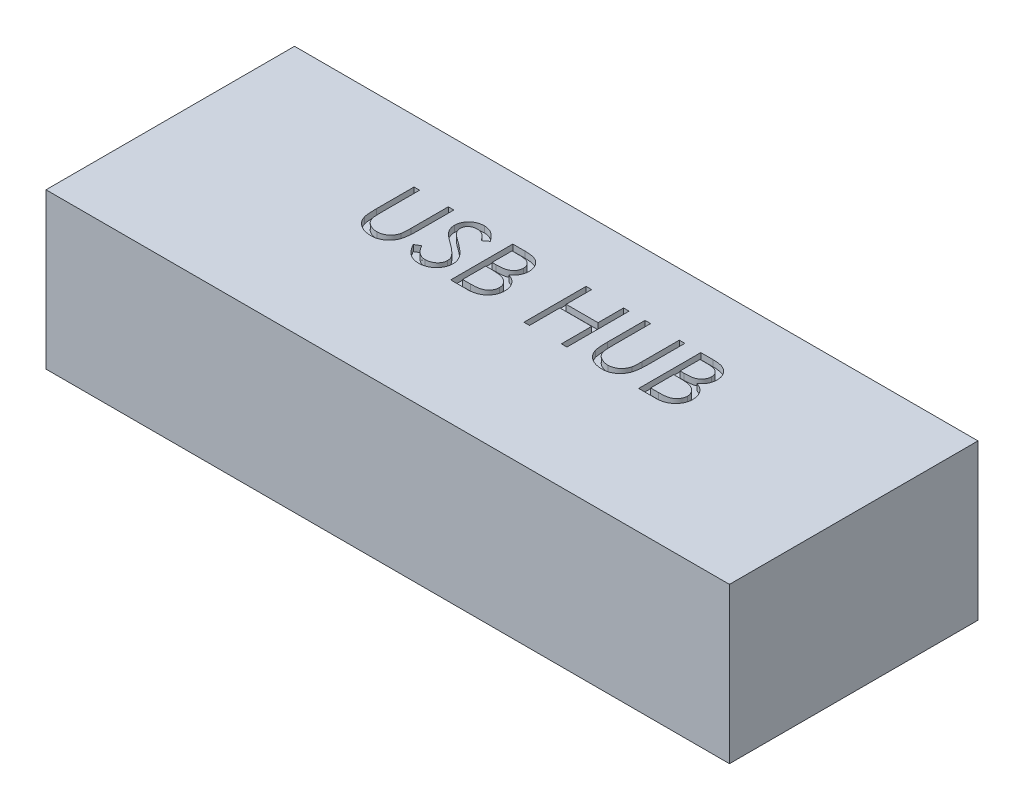
from build123d import *

# Parameters (mm, degrees)
SKETCH1_W           = 110
SKETCH1_H           = 40
BOSS_EXTRUDE1_DEPTH = 25
CUT_EXTRUDE1_DEPTH  = 1


with BuildPart() as part:
    # Sketch1 → Boss-Extrude1 (new body)
    with BuildSketch(Plane(origin=(0, 0, 0), x_dir=(1, 0, 0), z_dir=(0, 1, 0))):
        with Locations((55, 20)):
            Rectangle(SKETCH1_W, SKETCH1_H)
    extrude(amount=BOSS_EXTRUDE1_DEPTH)

    # Sketch2 → Cut-Extrude1 (cut)
    with BuildSketch(Plane(origin=(0, 25, 0), x_dir=(1, 0, 0), z_dir=(0, 1, 0))):
        with BuildLine():
            Line((29.230769231, 30), (30.128205128, 30))
            Line((30.128205128, 30), (30.128205128, 24.008413462))
            add(Edge.make_bspline(
                [(30.128205128, 24.008413462), (30.128071574, 23.923611359), (30.127818132, 23.762684757), (30.129511029, 23.533632469), (30.134252081, 23.329996872), (30.137241109, 23.150993022), (30.143890633, 22.997442315), (30.149313624, 22.868512856), (30.156286643, 22.764815135), (30.164666979, 22.704298203), (30.168269231, 22.678285256)],
                knots=[0, 0, 0, 0, 1.528628734, 2.90083645, 4.128790002, 5.200304208, 6.127813768, 6.898992206, 7.526736466, 8, 8, 8, 8], degree=3))
            add(Edge.make_bspline(
                [(30.168269231, 22.678285256), (30.18306197, 22.584437361), (30.211813931, 22.402029564), (30.285089296, 22.142291615), (30.387425013, 21.908201735), (30.50869085, 21.692455189), (30.668498311, 21.501057017), (30.859936983, 21.324738009), (31.091873464, 21.170532853), (31.349760909, 21.029530533), (31.627718731, 20.916201727), (31.91175092, 20.8305064), (32.197588004, 20.778280972), (32.388948475, 20.772233718), (32.483974359, 20.769230769)],
                knots=[0, 0, 0, 0, 1.035780045, 2.013197591, 2.933192213, 3.817615948, 4.702609284, 5.640816605, 6.646850145, 7.73207398, 8.84249596, 9.914020372, 10.964143139, 12, 12, 12, 12], degree=3))
            add(Edge.make_bspline(
                [(32.483974359, 20.769230769), (32.565556474, 20.772298913), (32.728249508, 20.778417479), (32.969982167, 20.816307282), (33.205411049, 20.884594613), (33.435698706, 20.972708208), (33.651558662, 21.089129897), (33.853111353, 21.22361801), (34.033008308, 21.38136337), (34.197174016, 21.555935783), (34.340130976, 21.75290664), (34.464048523, 21.967987034), (34.565551179, 22.20441374), (34.615675536, 22.370569232), (34.641426282, 22.455929487)],
                knots=[0, 0, 0, 0, 0.994687771, 1.983630487, 2.973142513, 3.978332533, 4.983357753, 5.956394766, 6.925816176, 7.893390482, 8.871859704, 9.88551698, 10.913711441, 12, 12, 12, 12], degree=3))
            add(Edge.make_bspline(
                [(34.641426282, 22.455929487), (34.649998069, 22.491211128), (34.669099463, 22.569832843), (34.686948163, 22.702750816), (34.705538236, 22.85957757), (34.718437007, 23.041439892), (34.731011923, 23.247728385), (34.738534988, 23.479517692), (34.742012225, 23.735966152), (34.743048455, 23.914929471), (34.743589744, 24.008413462)],
                knots=[0, 0, 0, 0, 0.558680831, 1.244966039, 2.062412453, 2.990489873, 4.051219941, 5.244515665, 6.560634259, 8, 8, 8, 8], degree=3))
            Line((34.743589744, 24.008413462), (34.743589744, 30))
            Line((34.743589744, 30), (35.641025641, 30))
            Line((35.641025641, 30), (35.641025641, 23.960336538))
            add(Edge.make_bspline(
                [(35.641025641, 23.960336538), (35.640299583, 23.851484027), (35.638882636, 23.639051733), (35.626595275, 23.327762136), (35.607003846, 23.032467904), (35.579323595, 22.753129342), (35.542646443, 22.49074603), (35.501860099, 22.243018121), (35.449918576, 22.011723856), (35.389251715, 21.795059806), (35.319898721, 21.588815482), (35.230066869, 21.393076583), (35.128854012, 21.201892584), (35.008812146, 21.01815513), (34.873922481, 20.841050692), (34.721203394, 20.671653335), (34.555705791, 20.50725606), (34.374678478, 20.352075871), (34.181105549, 20.209765366), (33.975562812, 20.084628877), (33.759629185, 19.978847113), (33.533865967, 19.891773043), (33.298176816, 19.82630276), (33.052555788, 19.7775166), (32.796443807, 19.74979575), (32.622259075, 19.74567595), (32.534054487, 19.743589744)],
                knots=[0, 0, 0, 0, 1.316592851, 2.569410997, 3.76748051, 4.895814652, 5.963796859, 6.97159953, 7.931736103, 8.829262218, 9.692595152, 10.560224239, 11.431080259, 12.30701507, 13.211635791, 14.121146779, 15.063487852, 16.031507147, 17.00238618, 17.966455255, 18.938106653, 19.907068911, 20.888905087, 21.893141452, 22.933117798, 24, 24, 24, 24], degree=3))
            add(Edge.make_bspline(
                [(32.534054487, 19.743589744), (32.437857051, 19.74583193), (32.249118026, 19.750231092), (31.971009262, 19.775438949), (31.704397273, 19.822920076), (31.446466195, 19.883377058), (31.200727632, 19.966759165), (30.96388922, 20.064182378), (30.740007274, 20.183831694), (30.525449763, 20.316955674), (30.32595046, 20.466740354), (30.142815023, 20.629997994), (29.975741107, 20.804113358), (29.827544831, 20.990971546), (29.695770875, 21.18911928), (29.58225598, 21.399117108), (29.484789568, 21.620883726), (29.434485091, 21.775035727), (29.409054487, 21.852964744)],
                knots=[0, 0, 0, 0, 1.13879206, 2.234305948, 3.301075583, 4.341971843, 5.366689343, 6.369221514, 7.369726634, 8.367512178, 9.355451585, 10.318319045, 11.268648973, 12.207971039, 13.137398894, 14.081662264, 15.030215811, 16, 16, 16, 16], degree=3))
            add(Edge.make_bspline(
                [(29.409054487, 21.852964744), (29.394262607, 21.906200671), (29.362178688, 22.021670582), (29.327820695, 22.212774835), (29.298937605, 22.432817457), (29.271778867, 22.681813509), (29.255753273, 22.959955985), (29.241703448, 23.267124316), (29.230670251, 23.603689921), (29.230735315, 23.838131394), (29.230769231, 23.960336538)],
                knots=[0, 0, 0, 0, 0.625038921, 1.35572334, 2.194682327, 3.136881307, 4.189498639, 5.346923369, 6.617055217, 8, 8, 8, 8], degree=3))
            Line((29.230769231, 23.960336538), (29.230769231, 30))
        make_face()
        with BuildLine():
            Line((37.179487179, 21.929086538), (38.024839744, 22.435897436))
            add(Edge.make_bspline(
                [(38.024839744, 22.435897436), (38.103463279, 22.304284907), (38.254102938, 22.052120382), (38.505392535, 21.711383124), (38.765772281, 21.421776961), (39.037170377, 21.184986654), (39.317930229, 20.998561264), (39.609884668, 20.866554887), (39.912049842, 20.784223529), (40.117689332, 20.774223282), (40.220352564, 20.769230769)],
                knots=[0, 0, 0, 0, 1.272034388, 2.437168799, 3.508375237, 4.49857839, 5.41946034, 6.295179144, 7.148887113, 8, 8, 8, 8], degree=3))
            add(Edge.make_bspline(
                [(40.220352564, 20.769230769), (40.308029308, 20.771672691), (40.48184866, 20.776513806), (40.737740783, 20.823030383), (40.986260218, 20.894493608), (41.222284897, 20.996839127), (41.442558081, 21.120663372), (41.635720068, 21.270223879), (41.802708963, 21.437670181), (41.939306433, 21.624477766), (42.044106534, 21.825383905), (42.124655301, 22.031600909), (42.169355511, 22.246368247), (42.176089093, 22.390969569), (42.179487179, 22.463942308)],
                knots=[0, 0, 0, 0, 1.095163259, 2.171163733, 3.241058638, 4.321873601, 5.38011039, 6.391990106, 7.366004449, 8.327778327, 9.272591725, 10.192022065, 11.087607919, 12, 12, 12, 12], degree=3))
            add(Edge.make_bspline(
                [(42.179487179, 22.463942308), (42.175274863, 22.547201878), (42.16671184, 22.716456419), (42.094336182, 22.966169713), (41.980481191, 23.213291342), (41.875445067, 23.3661521), (41.820913462, 23.445512821)],
                knots=[0, 0, 0, 0, 0.938893495, 1.908633276, 2.914225137, 4, 4, 4, 4], degree=3))
            add(Edge.make_bspline(
                [(41.820913462, 23.445512821), (41.776140278, 23.502789459), (41.68214458, 23.623034598), (41.520551687, 23.802020985), (41.330934218, 23.986645039), (41.119781204, 24.183956631), (40.87940095, 24.384778907), (40.617322337, 24.598688272), (40.326854169, 24.817549921), (40.123141321, 24.96432868), (40.018028846, 25.040064103)],
                knots=[0, 0, 0, 0, 0.722233717, 1.516239348, 2.393582979, 3.351407094, 4.387010283, 5.505090956, 6.712668013, 8, 8, 8, 8], degree=3))
            add(Edge.make_bspline(
                [(40.018028846, 25.040064103), (39.912817428, 25.115002924), (39.71166121, 25.258280245), (39.430350974, 25.470921057), (39.178795366, 25.665332112), (38.958112461, 25.843343575), (38.768399328, 26.004979589), (38.60816101, 26.148687987), (38.481479419, 26.278355303), (38.411034903, 26.362473423), (38.379407051, 26.400240385)],
                knots=[0, 0, 0, 0, 1.452282411, 2.77665338, 3.964542531, 5.026858415, 5.96415736, 6.766646006, 7.446254459, 8, 8, 8, 8], degree=3))
            add(Edge.make_bspline(
                [(38.379407051, 26.400240385), (38.335199779, 26.45910049), (38.248260246, 26.574856786), (38.13350023, 26.755784951), (38.035959765, 26.940994281), (37.959495959, 27.130982466), (37.895106762, 27.323082262), (37.851798389, 27.519800107), (37.824680112, 27.720253303), (37.821903007, 27.855149019), (37.820512821, 27.922676282)],
                knots=[0, 0, 0, 0, 1.068054152, 2.10047183, 3.106115577, 4.101338837, 5.06977816, 6.043150881, 7.020423561, 8, 8, 8, 8], degree=3))
            add(Edge.make_bspline(
                [(37.820512821, 27.922676282), (37.824241989, 28.028475638), (37.831620618, 28.237812963), (37.894022096, 28.543615336), (37.992516078, 28.835576528), (38.130501471, 29.110806053), (38.308379623, 29.362137427), (38.514225264, 29.592461675), (38.759400939, 29.786086196), (39.028408434, 29.955263505), (39.322855211, 30.087680435), (39.631400649, 30.187568949), (39.954535141, 30.244166828), (40.17340124, 30.252289014), (40.284455128, 30.256410256)],
                knots=[0, 0, 0, 0, 1.005424448, 1.989358655, 2.955360095, 3.929531133, 4.905563448, 5.876582895, 6.856512386, 7.866279853, 8.892233794, 9.918561126, 10.94386622, 12, 12, 12, 12], degree=3))
            add(Edge.make_bspline(
                [(40.284455128, 30.256410256), (40.402295415, 30.252345823), (40.636642134, 30.244262963), (40.981354179, 30.173984302), (41.31324194, 30.057696668), (41.580222696, 29.925729074), (41.789173443, 29.793925029), (41.948524108, 29.673868388), (42.110002539, 29.535653792), (42.274911267, 29.378913089), (42.440456008, 29.202208086), (42.609094443, 29.006748975), (42.781220926, 28.793730244), (42.891951955, 28.641660242), (42.948717949, 28.563701923)],
                knots=[0, 0, 0, 0, 1.286793592, 2.559021753, 3.825965368, 5.121522368, 5.803751409, 6.523245864, 7.299691795, 8.125521123, 9.008227632, 9.944561021, 10.946284179, 12, 12, 12, 12], degree=3))
            Line((42.948717949, 28.563701923), (42.137419872, 27.948717949))
            add(Edge.make_bspline(
                [(42.137419872, 27.948717949), (42.088431493, 28.011828493), (41.99409133, 28.133364645), (41.850864225, 28.303568404), (41.715868088, 28.45904406), (41.582866946, 28.594087282), (41.458885142, 28.716093378), (41.338550735, 28.820549826), (41.223595446, 28.908480098), (41.078689987, 29.002318841), (40.896639363, 29.095337423), (40.668112117, 29.174049074), (40.429294188, 29.221349251), (40.266638098, 29.227603216), (40.184294872, 29.230769231)],
                knots=[0, 0, 0, 0, 1.181633172, 2.275549214, 3.290209073, 4.226197932, 5.078386478, 5.862611352, 6.581680152, 7.217281963, 8.414376989, 9.595101626, 10.782541182, 12, 12, 12, 12], degree=3))
            add(Edge.make_bspline(
                [(40.184294872, 29.230769231), (40.080990522, 29.227307231), (39.881777815, 29.22063109), (39.598948569, 29.147716847), (39.344394498, 29.032911531), (39.125672883, 28.872011594), (38.943567234, 28.681380186), (38.811837352, 28.462012029), (38.732551168, 28.219776593), (38.722876083, 28.050800432), (38.717948718, 27.96474359)],
                knots=[0, 0, 0, 0, 1.14458467, 2.207223713, 3.21896685, 4.227309161, 5.202851033, 6.127160689, 7.046193047, 8, 8, 8, 8], degree=3))
            add(Edge.make_bspline(
                [(38.717948718, 27.96474359), (38.719071937, 27.911167937), (38.721320212, 27.803929024), (38.752676776, 27.64549639), (38.792960573, 27.487463992), (38.856796664, 27.330542326), (38.944926103, 27.171987015), (39.060655177, 27.009067765), (39.206407497, 26.840348597), (39.318056104, 26.730613243), (39.377003205, 26.672676282)],
                knots=[0, 0, 0, 0, 0.858281714, 1.717966888, 2.583508476, 3.4729293, 4.427298488, 5.488583878, 6.674047936, 8, 8, 8, 8], degree=3))
            add(Edge.make_bspline(
                [(39.377003205, 26.672676282), (39.398892841, 26.653141923), (39.450897604, 26.606732756), (39.545971677, 26.530754811), (39.671522529, 26.437032605), (39.824271676, 26.321068843), (40.007035566, 26.18655038), (40.219834298, 26.035197203), (40.460295821, 25.862095891), (40.630929866, 25.741074346), (40.721153846, 25.677083333)],
                knots=[0, 0, 0, 0, 0.420754252, 0.999615792, 1.744751191, 2.668019286, 3.750313428, 4.999500688, 6.413464383, 8, 8, 8, 8], degree=3))
            add(Edge.make_bspline(
                [(40.721153846, 25.677083333), (40.829685027, 25.59810802), (41.039840617, 25.445183272), (41.338862274, 25.215424187), (41.60998744, 24.990716276), (41.854168021, 24.772494542), (42.073816331, 24.562414276), (42.266495533, 24.357948047), (42.434168905, 24.160560696), (42.614680958, 23.907496194), (42.799131871, 23.596693096), (42.957536178, 23.215898129), (43.057417171, 22.833622928), (43.070478643, 22.576689109), (43.076923077, 22.449919872)],
                knots=[0, 0, 0, 0, 1.163667725, 2.253281268, 3.268753668, 4.215851969, 5.092017293, 5.902905408, 6.650798638, 7.335211899, 8.59617414, 9.77448103, 10.901945474, 12, 12, 12, 12], degree=3))
            add(Edge.make_bspline(
                [(43.076923077, 22.449919872), (43.075045539, 22.3602674), (43.071326925, 22.182703447), (43.028581457, 21.921974656), (42.965953842, 21.6687436), (42.871561745, 21.426140421), (42.756352722, 21.189726814), (42.610163442, 20.965704241), (42.440712914, 20.749114531), (42.246330729, 20.545733127), (42.033628151, 20.35902971), (41.808817595, 20.192946677), (41.5715311, 20.054465753), (41.32305591, 19.941463347), (41.063334948, 19.853081869), (40.792455566, 19.7890451), (40.509971248, 19.749743068), (40.317969872, 19.74566375), (40.220352564, 19.743589744)],
                knots=[0, 0, 0, 0, 0.983748083, 1.948392443, 2.894712957, 3.844097841, 4.80183111, 5.778335162, 6.776009319, 7.81870978, 8.863265674, 9.881300176, 10.883814829, 11.87499822, 12.874611388, 13.892143829, 14.928324115, 16, 16, 16, 16], degree=3))
            add(Edge.make_bspline(
                [(40.220352564, 19.743589744), (40.144823013, 19.745050262), (39.994715127, 19.747952906), (39.772688036, 19.773613708), (39.555146352, 19.809919718), (39.344819832, 19.867559918), (39.138998656, 19.937494138), (38.938577986, 20.02360366), (38.743460689, 20.126795664), (38.55255331, 20.244781448), (38.366341382, 20.38208929), (38.186571474, 20.542013566), (38.00734523, 20.72014358), (37.833952669, 20.921316618), (37.662886542, 21.142282569), (37.497519658, 21.385108807), (37.334429036, 21.648472675), (37.232099128, 21.833801492), (37.179487179, 21.929086538)],
                knots=[0, 0, 0, 0, 0.915332311, 1.819136955, 2.706846663, 3.586547465, 4.459518054, 5.340707479, 6.227863349, 7.133153174, 8.059268498, 9.028702269, 10.047606654, 11.120612155, 12.245963614, 13.433783089, 14.680604001, 16, 16, 16, 16], degree=3))
        make_face()
        with BuildLine():
            Line((45.128205128, 30), (47.079326923, 30))
            add(Edge.make_bspline(
                [(47.079326923, 30), (47.174836861, 29.999497856), (47.35995889, 29.998524576), (47.629157296, 29.983429916), (47.881296754, 29.962848002), (48.11645039, 29.930190594), (48.334509539, 29.890785516), (48.53613136, 29.843066042), (48.720674709, 29.785847146), (48.940996813, 29.694857771), (49.192198702, 29.559648718), (49.464194109, 29.359852818), (49.69677765, 29.115474352), (49.897309985, 28.839809622), (50.056741756, 28.53656456), (50.172082605, 28.212966878), (50.245105106, 27.873190472), (50.252614918, 27.63992425), (50.256410256, 27.522035256)],
                knots=[0, 0, 0, 0, 1.001505555, 1.941167018, 2.826882275, 3.653841531, 4.429895133, 5.150066043, 5.825578002, 6.45369114, 7.647487171, 8.808567382, 9.977351308, 11.170798116, 12.373658725, 13.556498008, 14.765093433, 16, 16, 16, 16], degree=3))
            add(Edge.make_bspline(
                [(50.256410256, 27.522035256), (50.253286775, 27.411599383), (50.24714884, 27.194582477), (50.188455242, 26.877170736), (50.096567618, 26.575024397), (49.968838334, 26.289246153), (49.802832631, 26.026292972), (49.606094578, 25.784043641), (49.368732285, 25.572754907), (49.190894456, 25.454632328), (49.100560897, 25.39463141)],
                knots=[0, 0, 0, 0, 1.044552857, 2.05264487, 3.044412934, 4.028983338, 5.005914585, 5.980388656, 6.974128949, 8, 8, 8, 8], degree=3))
            add(Edge.make_bspline(
                [(49.100560897, 25.39463141), (49.214162119, 25.351017128), (49.431509397, 25.267572201), (49.73061229, 25.120042304), (49.988311847, 24.959579131), (50.206589407, 24.784345273), (50.393268421, 24.595462957), (50.556276826, 24.390162631), (50.695366466, 24.165766179), (50.814546248, 23.924613221), (50.907542694, 23.669166169), (50.977188135, 23.401821094), (51.017095132, 23.123536651), (51.022774107, 22.934149853), (51.025641026, 22.838541667)],
                knots=[0, 0, 0, 0, 1.27268992, 2.434971085, 3.483601985, 4.442670788, 5.356604649, 6.2567628, 7.179492994, 8.113709626, 9.066344395, 10.018646069, 10.999752585, 12, 12, 12, 12], degree=3))
            add(Edge.make_bspline(
                [(51.025641026, 22.838541667), (51.022850037, 22.740922032), (51.017358689, 22.548852666), (50.976844484, 22.266695139), (50.908247035, 21.997052434), (50.813758045, 21.738180484), (50.690437147, 21.490580099), (50.540357248, 21.253970774), (50.361409924, 21.030729829), (50.161230298, 20.81837662), (49.934767025, 20.627440085), (49.690436297, 20.457395209), (49.425161097, 20.317549317), (49.143298257, 20.20007497), (48.841685926, 20.110340117), (48.521678476, 20.047561334), (48.183551899, 20.005261229), (47.951524039, 20.0017835), (47.832532051, 20)],
                knots=[0, 0, 0, 0, 0.978564426, 1.925352924, 2.850884081, 3.763762016, 4.682927383, 5.618979971, 6.567305752, 7.547517671, 8.540179244, 9.531824382, 10.526200242, 11.540722885, 12.589160233, 13.674978461, 14.80764778, 16, 16, 16, 16], degree=3))
            Line((47.832532051, 20), (45.128205128, 20))
            Line((45.128205128, 20), (45.128205128, 30))
        make_face()
        with BuildLine():
            Line((46.025641026, 28.974358974), (46.025641026, 25.769230769))
            Line((46.025641026, 25.769230769), (46.628605769, 25.769230769))
            add(Edge.make_bspline(
                [(46.628605769, 25.769230769), (46.716745185, 25.770373406), (46.887048497, 25.772581214), (47.133676773, 25.778905549), (47.362605396, 25.796614244), (47.573439205, 25.81431785), (47.765846188, 25.843102386), (47.939400078, 25.877365595), (48.09682464, 25.913602466), (48.278366199, 25.975229572), (48.484288909, 26.066308644), (48.703812064, 26.207656747), (48.897339119, 26.376012042), (49.060759656, 26.570271932), (49.194506714, 26.784175321), (49.287403044, 27.014309265), (49.350395284, 27.254938213), (49.356085374, 27.420133221), (49.358974359, 27.50400641)],
                knots=[0, 0, 0, 0, 1.156816544, 2.235205308, 3.236616184, 4.169592532, 5.011045266, 5.787822928, 6.49130361, 7.128639758, 8.301311294, 9.436451833, 10.541879658, 11.654887649, 12.756523258, 13.837046038, 14.901820046, 16, 16, 16, 16], degree=3))
            add(Edge.make_bspline(
                [(49.358974359, 27.50400641), (49.357470987, 27.559508615), (49.354521959, 27.668382249), (49.330369666, 27.82709469), (49.289319453, 27.976362554), (49.236592901, 28.118231441), (49.162910933, 28.248265298), (49.076158181, 28.370960143), (48.971341923, 28.482137625), (48.852035315, 28.586050477), (48.714867821, 28.678177699), (48.559921273, 28.758865594), (48.385099339, 28.823839242), (48.193348325, 28.880742534), (47.981716646, 28.920709088), (47.752646493, 28.954004482), (47.504261582, 28.970955173), (47.332418432, 28.973199067), (47.243589744, 28.974358974)],
                knots=[0, 0, 0, 0, 0.91205012, 1.789085906, 2.630437955, 3.453916878, 4.269457761, 5.079663411, 5.91843418, 6.774407191, 7.675494373, 8.627863946, 9.638891023, 10.736472738, 11.911756761, 13.175263542, 14.539845004, 16, 16, 16, 16], degree=3))
            Line((47.243589744, 28.974358974), (46.025641026, 28.974358974))
        make_face(mode=Mode.SUBTRACT)
        with BuildLine():
            Line((46.025641026, 24.743589744), (46.025641026, 21.025641026))
            Line((46.025641026, 21.025641026), (47.303685897, 21.025641026))
            add(Edge.make_bspline(
                [(47.303685897, 21.025641026), (47.395168543, 21.026737447), (47.571489282, 21.028850654), (47.826064225, 21.035749381), (48.06201595, 21.051441598), (48.278267766, 21.076144025), (48.477154774, 21.102939594), (48.656291068, 21.138971825), (48.817128764, 21.18025457), (49.003626786, 21.24406649), (49.21363681, 21.343199265), (49.439953542, 21.492668483), (49.641171308, 21.670735076), (49.812043477, 21.876823403), (49.952080588, 22.100912908), (50.053953316, 22.338471051), (50.116784336, 22.585572558), (50.124390534, 22.754048879), (50.128205128, 22.838541667)],
                knots=[0, 0, 0, 0, 1.160039823, 2.235823828, 3.228722157, 4.157150951, 4.99529583, 5.772374946, 6.472645482, 7.099169577, 8.269452708, 9.405989375, 10.527446681, 11.663510218, 12.788923519, 13.866172445, 14.929861265, 16, 16, 16, 16], degree=3))
            add(Edge.make_bspline(
                [(50.128205128, 22.838541667), (50.127416259, 22.891379782), (50.125851244, 22.99620373), (50.102249487, 23.150248928), (50.067924145, 23.299465709), (50.02354862, 23.444259253), (49.958921571, 23.582011757), (49.883474299, 23.715447641), (49.795013152, 23.844743297), (49.657172678, 24.008206878), (49.456681293, 24.196541201), (49.171804792, 24.380934064), (48.847883941, 24.529642085), (48.612948247, 24.592783446), (48.491586538, 24.625400641)],
                knots=[0, 0, 0, 0, 0.723448775, 1.435228256, 2.130040452, 2.821711965, 3.505591119, 4.210454504, 4.921174351, 5.648778258, 7.137944449, 8.670945889, 10.280296675, 12, 12, 12, 12], degree=3))
            add(Edge.make_bspline(
                [(48.491586538, 24.625400641), (48.442931979, 24.635272309), (48.337438858, 24.656676123), (48.1654172, 24.679269561), (47.969029003, 24.699398304), (47.747820782, 24.714287326), (47.501512665, 24.72967745), (47.229578611, 24.735662653), (46.933129141, 24.742803396), (46.727436648, 24.743320923), (46.620592949, 24.743589744)],
                knots=[0, 0, 0, 0, 0.634451884, 1.375622551, 2.216452059, 3.157844607, 4.20941857, 5.370758133, 6.634282058, 8, 8, 8, 8], degree=3))
            Line((46.620592949, 24.743589744), (46.025641026, 24.743589744))
        make_face(mode=Mode.SUBTRACT)
        Polygon((56.923076923, 30), (57.820512821, 30), (57.820512821, 25.897435897), (62.948717949, 25.897435897), (62.948717949, 30), (63.846153846, 30), (63.846153846, 20), (62.948717949, 20), (62.948717949, 24.871794872), (57.820512821, 24.871794872), (57.820512821, 20), (56.923076923, 20), align=None)
        with BuildLine():
            Line((66.41025641, 30), (67.307692308, 30))
            Line((67.307692308, 30), (67.307692308, 24.008413462))
            add(Edge.make_bspline(
                [(67.307692308, 24.008413462), (67.307558753, 23.923611359), (67.307305311, 23.762684757), (67.308998208, 23.533632469), (67.313739261, 23.329996872), (67.316728288, 23.150993022), (67.323377812, 22.997442315), (67.328800804, 22.868512856), (67.335773823, 22.764815135), (67.344154158, 22.704298203), (67.34775641, 22.678285256)],
                knots=[0, 0, 0, 0, 1.528628734, 2.90083645, 4.128790002, 5.200304208, 6.127813768, 6.898992206, 7.526736466, 8, 8, 8, 8], degree=3))
            add(Edge.make_bspline(
                [(67.34775641, 22.678285256), (67.36254915, 22.584437361), (67.391301111, 22.402029564), (67.464576476, 22.142291615), (67.566912193, 21.908201735), (67.688178029, 21.692455189), (67.84798549, 21.501057017), (68.039424162, 21.324738009), (68.271360644, 21.170532853), (68.529248089, 21.029530533), (68.80720591, 20.916201727), (69.0912381, 20.8305064), (69.377075183, 20.778280972), (69.568435655, 20.772233718), (69.663461538, 20.769230769)],
                knots=[0, 0, 0, 0, 1.035780045, 2.013197591, 2.933192213, 3.817615948, 4.702609284, 5.640816605, 6.646850145, 7.73207398, 8.84249596, 9.914020372, 10.964143139, 12, 12, 12, 12], degree=3))
            add(Edge.make_bspline(
                [(69.663461538, 20.769230769), (69.745043654, 20.772298913), (69.907736688, 20.778417479), (70.149469347, 20.816307282), (70.384898229, 20.884594613), (70.615185886, 20.972708208), (70.831045841, 21.089129897), (71.032598533, 21.22361801), (71.212495488, 21.38136337), (71.376661196, 21.555935783), (71.519618155, 21.75290664), (71.643535703, 21.967987034), (71.745038359, 22.20441374), (71.795162716, 22.370569232), (71.820913462, 22.455929487)],
                knots=[0, 0, 0, 0, 0.994687771, 1.983630487, 2.973142513, 3.978332533, 4.983357753, 5.956394766, 6.925816176, 7.893390482, 8.871859704, 9.88551698, 10.913711441, 12, 12, 12, 12], degree=3))
            add(Edge.make_bspline(
                [(71.820913462, 22.455929487), (71.829485248, 22.491211128), (71.848586643, 22.569832843), (71.866435343, 22.702750816), (71.885025416, 22.85957757), (71.897924187, 23.041439892), (71.910499102, 23.247728385), (71.918022168, 23.479517692), (71.921499404, 23.735966152), (71.922535634, 23.914929471), (71.923076923, 24.008413462)],
                knots=[0, 0, 0, 0, 0.558680831, 1.244966039, 2.062412453, 2.990489873, 4.051219941, 5.244515665, 6.560634259, 8, 8, 8, 8], degree=3))
            Line((71.923076923, 24.008413462), (71.923076923, 30))
            Line((71.923076923, 30), (72.820512821, 30))
            Line((72.820512821, 30), (72.820512821, 23.960336538))
            add(Edge.make_bspline(
                [(72.820512821, 23.960336538), (72.819786762, 23.851484027), (72.818369815, 23.639051733), (72.806082454, 23.327762136), (72.786491026, 23.032467904), (72.758810775, 22.753129342), (72.722133623, 22.49074603), (72.681347278, 22.243018121), (72.629405755, 22.011723856), (72.568738895, 21.795059806), (72.4993859, 21.588815482), (72.409554048, 21.393076583), (72.308341191, 21.201892584), (72.188299326, 21.01815513), (72.053409661, 20.841050692), (71.900690573, 20.671653335), (71.73519297, 20.50725606), (71.554165657, 20.352075871), (71.360592728, 20.209765366), (71.155049992, 20.084628877), (70.939116364, 19.978847113), (70.713353147, 19.891773043), (70.477663995, 19.82630276), (70.232042968, 19.7775166), (69.975930987, 19.74979575), (69.801746255, 19.74567595), (69.713541667, 19.743589744)],
                knots=[0, 0, 0, 0, 1.316592851, 2.569410997, 3.76748051, 4.895814652, 5.963796859, 6.97159953, 7.931736103, 8.829262218, 9.692595152, 10.560224239, 11.431080259, 12.30701507, 13.211635791, 14.121146779, 15.063487852, 16.031507147, 17.00238618, 17.966455255, 18.938106653, 19.907068911, 20.888905087, 21.893141452, 22.933117798, 24, 24, 24, 24], degree=3))
            add(Edge.make_bspline(
                [(69.713541667, 19.743589744), (69.617344231, 19.74583193), (69.428605205, 19.750231092), (69.150496442, 19.775438949), (68.883884452, 19.822920076), (68.625953375, 19.883377058), (68.380214812, 19.966759165), (68.143376399, 20.064182378), (67.919494453, 20.183831694), (67.704936943, 20.316955674), (67.50543764, 20.466740354), (67.322302202, 20.629997994), (67.155228286, 20.804113358), (67.007032011, 20.990971546), (66.875258055, 21.18911928), (66.761743159, 21.399117108), (66.664276748, 21.620883726), (66.61397227, 21.775035727), (66.588541667, 21.852964744)],
                knots=[0, 0, 0, 0, 1.13879206, 2.234305948, 3.301075583, 4.341971843, 5.366689343, 6.369221514, 7.369726634, 8.367512178, 9.355451585, 10.318319045, 11.268648973, 12.207971039, 13.137398894, 14.081662264, 15.030215811, 16, 16, 16, 16], degree=3))
            add(Edge.make_bspline(
                [(66.588541667, 21.852964744), (66.573749786, 21.906200671), (66.541665868, 22.021670582), (66.507307875, 22.212774835), (66.478424784, 22.432817457), (66.451266047, 22.681813509), (66.435240452, 22.959955985), (66.421190627, 23.267124316), (66.410157431, 23.603689921), (66.410222495, 23.838131394), (66.41025641, 23.960336538)],
                knots=[0, 0, 0, 0, 0.625038921, 1.35572334, 2.194682327, 3.136881307, 4.189498639, 5.346923369, 6.617055217, 8, 8, 8, 8], degree=3))
            Line((66.41025641, 23.960336538), (66.41025641, 30))
        make_face()
        with BuildLine():
            Line((75.384615385, 30), (77.335737179, 30))
            add(Edge.make_bspline(
                [(77.335737179, 30), (77.431247117, 29.999497856), (77.616369147, 29.998524576), (77.885567552, 29.983429916), (78.137707011, 29.962848002), (78.372860646, 29.930190594), (78.590919796, 29.890785516), (78.792541617, 29.843066042), (78.977084966, 29.785847146), (79.19740707, 29.694857771), (79.448608958, 29.559648718), (79.720604366, 29.359852818), (79.953187907, 29.115474352), (80.153720242, 28.839809622), (80.313152012, 28.53656456), (80.428492862, 28.212966878), (80.501515363, 27.873190472), (80.509025175, 27.63992425), (80.512820513, 27.522035256)],
                knots=[0, 0, 0, 0, 1.001505555, 1.941167018, 2.826882275, 3.653841531, 4.429895133, 5.150066043, 5.825578002, 6.45369114, 7.647487171, 8.808567382, 9.977351308, 11.170798116, 12.373658725, 13.556498008, 14.765093433, 16, 16, 16, 16], degree=3))
            add(Edge.make_bspline(
                [(80.512820513, 27.522035256), (80.509697032, 27.411599383), (80.503559096, 27.194582477), (80.444865498, 26.877170736), (80.352977874, 26.575024397), (80.225248591, 26.289246153), (80.059242887, 26.026292972), (79.862504834, 25.784043641), (79.625142541, 25.572754907), (79.447304713, 25.454632328), (79.356971154, 25.39463141)],
                knots=[0, 0, 0, 0, 1.044552857, 2.05264487, 3.044412934, 4.028983338, 5.005914585, 5.980388656, 6.974128949, 8, 8, 8, 8], degree=3))
            add(Edge.make_bspline(
                [(79.356971154, 25.39463141), (79.470572376, 25.351017128), (79.687919654, 25.267572201), (79.987022546, 25.120042304), (80.244722104, 24.959579131), (80.462999664, 24.784345273), (80.649678678, 24.595462957), (80.812687082, 24.390162631), (80.951776723, 24.165766179), (81.070956504, 23.924613221), (81.16395295, 23.669166169), (81.233598391, 23.401821094), (81.273505389, 23.123536651), (81.279184364, 22.934149853), (81.282051282, 22.838541667)],
                knots=[0, 0, 0, 0, 1.27268992, 2.434971085, 3.483601985, 4.442670788, 5.356604649, 6.2567628, 7.179492994, 8.113709626, 9.066344395, 10.018646069, 10.999752585, 12, 12, 12, 12], degree=3))
            add(Edge.make_bspline(
                [(81.282051282, 22.838541667), (81.279260293, 22.740922032), (81.273768945, 22.548852666), (81.23325474, 22.266695139), (81.164657291, 21.997052434), (81.070168302, 21.738180484), (80.946847403, 21.490580099), (80.796767505, 21.253970774), (80.61782018, 21.030729829), (80.417640555, 20.81837662), (80.191177282, 20.627440085), (79.946846553, 20.457395209), (79.681571354, 20.317549317), (79.399708514, 20.20007497), (79.098096182, 20.110340117), (78.778088732, 20.047561334), (78.439962156, 20.005261229), (78.207934295, 20.0017835), (78.088942308, 20)],
                knots=[0, 0, 0, 0, 0.978564426, 1.925352924, 2.850884081, 3.763762016, 4.682927383, 5.618979971, 6.567305752, 7.547517671, 8.540179244, 9.531824382, 10.526200242, 11.540722885, 12.589160233, 13.674978461, 14.80764778, 16, 16, 16, 16], degree=3))
            Line((78.088942308, 20), (75.384615385, 20))
            Line((75.384615385, 20), (75.384615385, 30))
        make_face()
        with BuildLine():
            Line((76.282051282, 28.974358974), (76.282051282, 25.769230769))
            Line((76.282051282, 25.769230769), (76.885016026, 25.769230769))
            add(Edge.make_bspline(
                [(76.885016026, 25.769230769), (76.973155441, 25.770373406), (77.143458753, 25.772581214), (77.390087029, 25.778905549), (77.619015652, 25.796614244), (77.829849461, 25.81431785), (78.022256444, 25.843102386), (78.195810334, 25.877365595), (78.353234897, 25.913602466), (78.534776455, 25.975229572), (78.740699165, 26.066308644), (78.96022232, 26.207656747), (79.153749376, 26.376012042), (79.317169912, 26.570271932), (79.450916971, 26.784175321), (79.5438133, 27.014309265), (79.60680554, 27.254938213), (79.61249563, 27.420133221), (79.615384615, 27.50400641)],
                knots=[0, 0, 0, 0, 1.156816544, 2.235205308, 3.236616184, 4.169592532, 5.011045266, 5.787822928, 6.49130361, 7.128639758, 8.301311294, 9.436451833, 10.541879658, 11.654887649, 12.756523258, 13.837046038, 14.901820046, 16, 16, 16, 16], degree=3))
            add(Edge.make_bspline(
                [(79.615384615, 27.50400641), (79.613881243, 27.559508615), (79.610932215, 27.668382249), (79.586779922, 27.82709469), (79.545729709, 27.976362554), (79.493003157, 28.118231441), (79.419321189, 28.248265298), (79.332568437, 28.370960143), (79.227752179, 28.482137625), (79.108445572, 28.586050477), (78.971278078, 28.678177699), (78.81633153, 28.758865594), (78.641509595, 28.823839242), (78.449758581, 28.880742534), (78.238126902, 28.920709088), (78.00905675, 28.954004482), (77.760671838, 28.970955173), (77.588828688, 28.973199067), (77.5, 28.974358974)],
                knots=[0, 0, 0, 0, 0.91205012, 1.789085906, 2.630437955, 3.453916878, 4.269457761, 5.079663411, 5.91843418, 6.774407191, 7.675494373, 8.627863946, 9.638891023, 10.736472738, 11.911756761, 13.175263542, 14.539845004, 16, 16, 16, 16], degree=3))
            Line((77.5, 28.974358974), (76.282051282, 28.974358974))
        make_face(mode=Mode.SUBTRACT)
        with BuildLine():
            Line((76.282051282, 24.743589744), (76.282051282, 21.025641026))
            Line((76.282051282, 21.025641026), (77.560096154, 21.025641026))
            add(Edge.make_bspline(
                [(77.560096154, 21.025641026), (77.651578799, 21.026737447), (77.827899538, 21.028850654), (78.082474481, 21.035749381), (78.318426206, 21.051441598), (78.534678023, 21.076144025), (78.73356503, 21.102939594), (78.912701325, 21.138971825), (79.07353902, 21.18025457), (79.260037042, 21.24406649), (79.470047066, 21.343199265), (79.696363799, 21.492668483), (79.897581565, 21.670735076), (80.068453734, 21.876823403), (80.208490844, 22.100912908), (80.310363573, 22.338471051), (80.373194592, 22.585572558), (80.38080079, 22.754048879), (80.384615385, 22.838541667)],
                knots=[0, 0, 0, 0, 1.160039823, 2.235823828, 3.228722157, 4.157150951, 4.99529583, 5.772374946, 6.472645482, 7.099169577, 8.269452708, 9.405989375, 10.527446681, 11.663510218, 12.788923519, 13.866172445, 14.929861265, 16, 16, 16, 16], degree=3))
            add(Edge.make_bspline(
                [(80.384615385, 22.838541667), (80.383826515, 22.891379782), (80.382261501, 22.99620373), (80.358659744, 23.150248928), (80.324334401, 23.299465709), (80.279958876, 23.444259253), (80.215331827, 23.582011757), (80.139884556, 23.715447641), (80.051423408, 23.844743297), (79.913582934, 24.008206878), (79.71309155, 24.196541201), (79.428215049, 24.380934064), (79.104294197, 24.529642085), (78.869358503, 24.592783446), (78.747996795, 24.625400641)],
                knots=[0, 0, 0, 0, 0.723448775, 1.435228256, 2.130040452, 2.821711965, 3.505591119, 4.210454504, 4.921174351, 5.648778258, 7.137944449, 8.670945889, 10.280296675, 12, 12, 12, 12], degree=3))
            add(Edge.make_bspline(
                [(78.747996795, 24.625400641), (78.699342235, 24.635272309), (78.593849114, 24.656676123), (78.421827456, 24.679269561), (78.225439259, 24.699398304), (78.004231038, 24.714287326), (77.757922921, 24.72967745), (77.485988868, 24.735662653), (77.189539397, 24.742803396), (76.983846905, 24.743320923), (76.877003205, 24.743589744)],
                knots=[0, 0, 0, 0, 0.634451884, 1.375622551, 2.216452059, 3.157844607, 4.20941857, 5.370758133, 6.634282058, 8, 8, 8, 8], degree=3))
            Line((76.877003205, 24.743589744), (76.282051282, 24.743589744))
        make_face(mode=Mode.SUBTRACT)
    extrude(amount=-CUT_EXTRUDE1_DEPTH, mode=Mode.SUBTRACT)


solid = part.part
